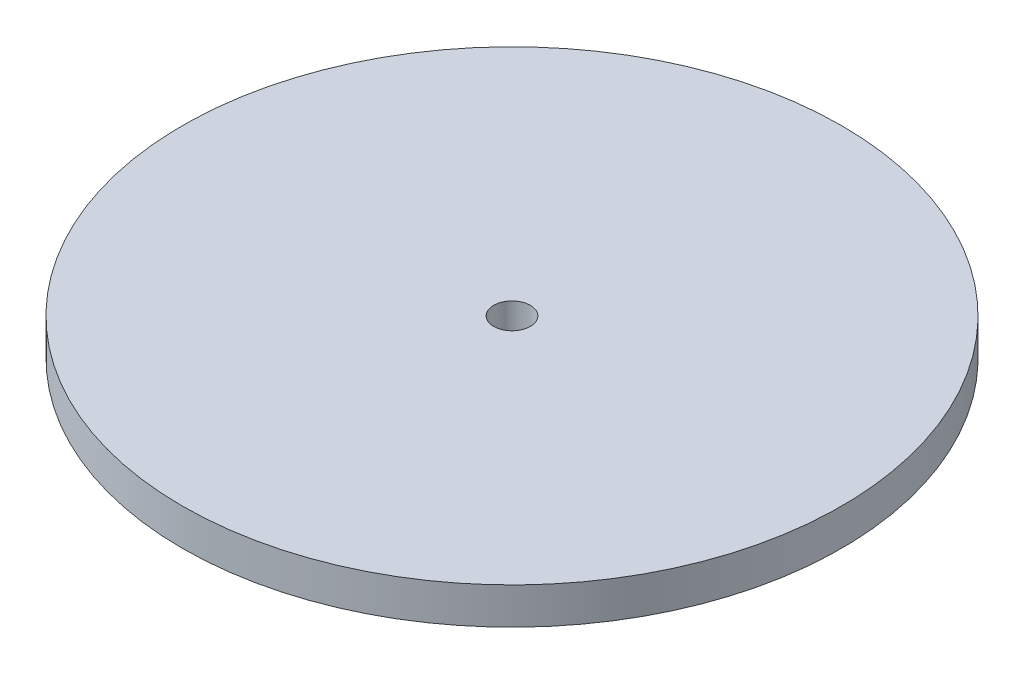
from build123d import *

# Parameters (mm, degrees)
SKETCH_1_R          = 90
EXTRUDE_1_DEPTH     = 10
SKETCH_2_R          = 5
CUT_EXTRUDE_1_DEPTH = 10


with BuildPart() as part:
    # 草图1 → 凸台-拉伸1 (new body)
    with BuildSketch(Plane(origin=(0, 0, 0), x_dir=(1, 0, 0), z_dir=(0, 1, 0))):
        Circle(SKETCH_1_R)
    extrude(amount=EXTRUDE_1_DEPTH)

    # 草图2 → 切除-拉伸1 (cut)
    with BuildSketch(Plane(origin=(0, 10, 0), x_dir=(1, 0, 0), z_dir=(0, 1, 0))):
        Circle(SKETCH_2_R)
    extrude(amount=-CUT_EXTRUDE_1_DEPTH, mode=Mode.SUBTRACT)


solid = part.part
